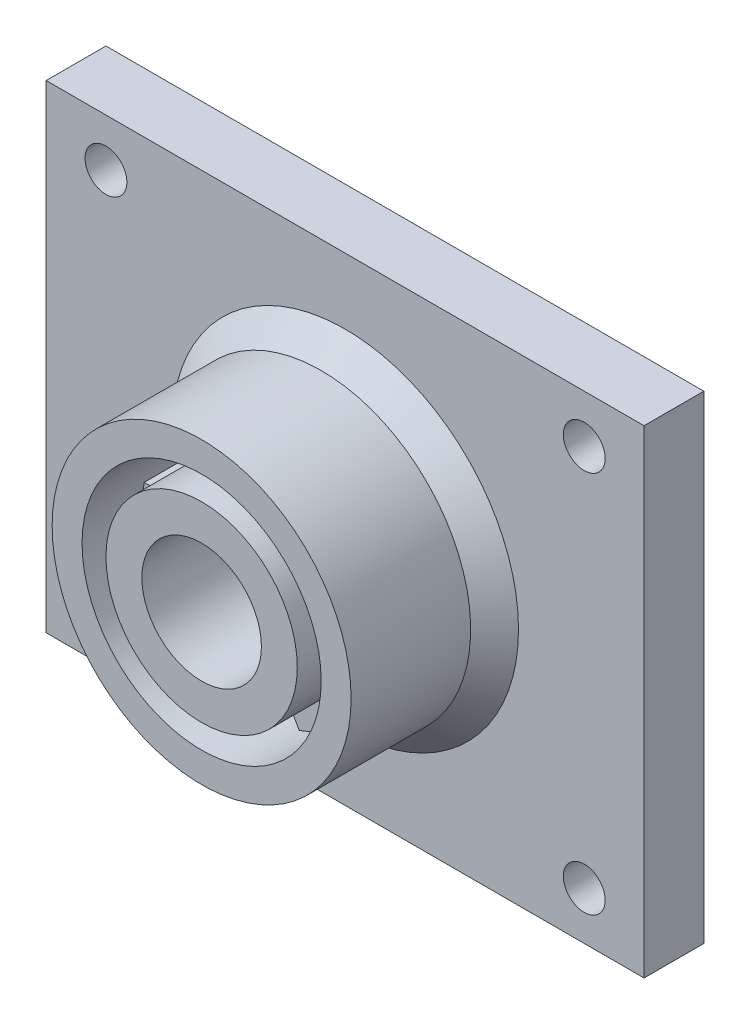
from build123d import *

# Parameters (mm, degrees)
CROQUIS1_W              = 50
CROQUIS1_H              = 40
CROQUIS1_R              = 1.75
SALIENTE_EXTRUIR1_DEPTH = 2.5
CROQUIS2_R              = 12.5
CROQUIS2_R_2            = 10
CROQUIS2_R_3            = 8
CROQUIS2_R_4            = 5
SALIENTE_EXTRUIR2_DEPTH = 7
CROQUIS4_R              = 12.5
CROQUIS4_R_2            = 5
SALIENTE_EXTRUIR3_DEPTH = 5
CHAFL_N1_SIZE           = 2


with BuildPart() as part:
    # Croquis1 → Saliente-Extruir1 (new, symmetric)
    with BuildSketch(Plane.XY):
        Rectangle(CROQUIS1_W, CROQUIS1_H)
        with Locations((-20, 16)):
            Circle(CROQUIS1_R, mode=Mode.SUBTRACT)
        with Locations((20, 16)):
            Circle(CROQUIS1_R, mode=Mode.SUBTRACT)
        with Locations((20, -16)):
            Circle(CROQUIS1_R, mode=Mode.SUBTRACT)
        with Locations((-20, -16)):
            Circle(CROQUIS1_R, mode=Mode.SUBTRACT)
    extrude(amount=SALIENTE_EXTRUIR1_DEPTH, both=True)

    # Croquis2 → Saliente-Extruir2 (add)
    with BuildSketch(Plane.XY.offset(2.5)):
        with Locations(Location((0, 0, 0), (0, 0, 180))):
            Circle(CROQUIS2_R)
        Circle(CROQUIS2_R_2, mode=Mode.SUBTRACT)
        with BuildLine():
            ThreePointArc((-9.797958971, 2), (-10, 0), (-9.797958971, -2))
            Line((-9.797958971, -2), (-7.745966692, -2))
            ThreePointArc((-7.745966692, -2), (-8, 0), (-7.745966692, 2))
            Line((-7.745966692, 2), (-9.797958971, 2))
        make_face()
        with BuildLine():
            Line((-5.605034154, -5.708203932), (-6.631030293, -7.485281374))
            ThreePointArc((-6.631030293, -7.485281374), (-5, -8.660254038), (-3.166928678, -9.485281374))
            Line((-3.166928678, -9.485281374), (-2.140932539, -7.708203932))
            ThreePointArc((-2.140932539, -7.708203932), (-4, -6.92820323), (-5.605034154, -5.708203932))
        make_face()
        with BuildLine():
            Line((2.140932539, -7.708203932), (3.166928678, -9.485281374))
            ThreePointArc((3.166928678, -9.485281374), (5, -8.660254038), (6.631030293, -7.485281374))
            Line((6.631030293, -7.485281374), (5.605034154, -5.708203933))
            ThreePointArc((5.605034154, -5.708203933), (4, -6.92820323), (2.140932539, -7.708203932))
        make_face()
        with BuildLine():
            Line((7.745966692, -2), (9.797958971, -2))
            ThreePointArc((9.797958971, -2), (9.94936153, -1.00508962), (10, 0))
            ThreePointArc((10, 0), (9.94936153, 1.00508962), (9.797958971, 2))
            Line((9.797958971, 2), (7.745966692, 2))
            ThreePointArc((7.745966692, 2), (7.93623757, 1.00803434), (8, 0))
            ThreePointArc((8, 0), (7.93623757, -1.00803434), (7.745966692, -2))
        make_face()
        with BuildLine():
            ThreePointArc((6.631030293, 7.485281374), (5, 8.660254038), (3.166928678, 9.485281374))
            Line((3.166928678, 9.485281374), (2.140932539, 7.708203932))
            ThreePointArc((2.140932539, 7.708203932), (4, 6.92820323), (5.605034154, 5.708203932))
            Line((5.605034154, 5.708203932), (6.631030293, 7.485281374))
        make_face()
        with BuildLine():
            ThreePointArc((-3.166928678, 9.485281374), (-5, 8.660254038), (-6.631030293, 7.485281374))
            Line((-6.631030293, 7.485281374), (-5.605034154, 5.708203932))
            ThreePointArc((-5.605034154, 5.708203932), (-4, 6.92820323), (-2.140932539, 7.708203932))
            Line((-2.140932539, 7.708203932), (-3.166928678, 9.485281374))
        make_face()
        Circle(CROQUIS2_R_3)
        Circle(CROQUIS2_R_4, mode=Mode.SUBTRACT)
    extrude(amount=SALIENTE_EXTRUIR2_DEPTH)

    # Croquis4 → Saliente-Extruir3 (add)
    with BuildSketch(Plane.XY.offset(9.5)):
        with Locations(Location((0, 0, 0), (0, 0, 180))):
            Circle(CROQUIS4_R)
        with BuildLine():
            ThreePointArc((9.797958971, 2), (9.94936153, 1.00508962), (10, 0))
            ThreePointArc((10, 0), (9.94936153, -1.00508962), (9.797958971, -2))
            ThreePointArc((9.797958971, -2), (8.660254038, -5), (6.631030293, -7.485281374))
            ThreePointArc((6.631030293, -7.485281374), (5, -8.660254038), (3.166928678, -9.485281374))
            ThreePointArc((3.166928678, -9.485281374), (0, -10), (-3.166928678, -9.485281374))
            ThreePointArc((-3.166928678, -9.485281374), (-5, -8.660254038), (-6.631030293, -7.485281374))
            ThreePointArc((-6.631030293, -7.485281374), (-8.660254038, -5), (-9.797958971, -2))
            ThreePointArc((-9.797958971, -2), (-10, 0), (-9.797958971, 2))
            ThreePointArc((-9.797958971, 2), (-8.660254038, 5), (-6.631030293, 7.485281374))
            ThreePointArc((-6.631030293, 7.485281374), (-5, 8.660254038), (-3.166928678, 9.485281374))
            ThreePointArc((-3.166928678, 9.485281374), (0, 10), (3.166928678, 9.485281374))
            ThreePointArc((3.166928678, 9.485281374), (5, 8.660254038), (6.631030293, 7.485281374))
            ThreePointArc((6.631030293, 7.485281374), (8.660254038, 5), (9.797958971, 2))
        make_face(mode=Mode.SUBTRACT)
        with BuildLine():
            ThreePointArc((7.745966692, -2), (7.93623757, -1.00803434), (8, 0))
            ThreePointArc((8, 0), (7.93623757, 1.00803434), (7.745966692, 2))
            ThreePointArc((7.745966692, 2), (6.92820323, 4), (5.605034154, 5.708203932))
            ThreePointArc((5.605034154, 5.708203932), (4, 6.92820323), (2.140932539, 7.708203932))
            ThreePointArc((2.140932539, 7.708203932), (0, 8), (-2.140932539, 7.708203932))
            ThreePointArc((-2.140932539, 7.708203932), (-4, 6.92820323), (-5.605034154, 5.708203932))
            ThreePointArc((-5.605034154, 5.708203932), (-6.92820323, 4), (-7.745966692, 2))
            ThreePointArc((-7.745966692, 2), (-8, 0), (-7.745966692, -2))
            ThreePointArc((-7.745966692, -2), (-6.92820323, -4), (-5.605034154, -5.708203932))
            ThreePointArc((-5.605034154, -5.708203932), (-4, -6.92820323), (-2.140932539, -7.708203932))
            ThreePointArc((-2.140932539, -7.708203932), (0, -8), (2.140932539, -7.708203932))
            ThreePointArc((2.140932539, -7.708203932), (4, -6.92820323), (5.605034154, -5.708203933))
            ThreePointArc((5.605034154, -5.708203933), (6.92820323, -4), (7.745966692, -2))
        make_face()
        Circle(CROQUIS4_R_2, mode=Mode.SUBTRACT)
    extrude(amount=SALIENTE_EXTRUIR3_DEPTH)

    # Chaflán1
    chafl_n1_edges = [part.edges().sort_by_distance(p)[0] for p in [
        (12.5, 0, 2.5),
    ]]
    chamfer(chafl_n1_edges, length=CHAFL_N1_SIZE)


solid = part.part
